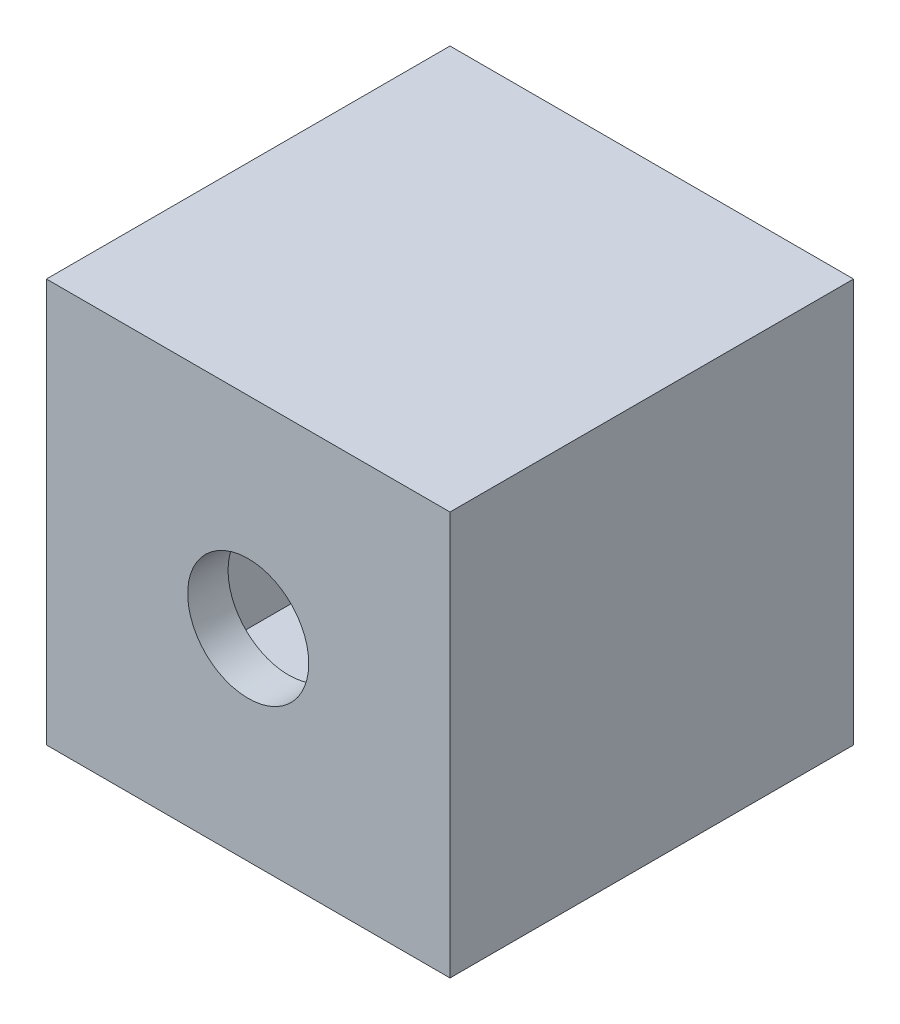
from build123d import *

# Parameters (mm, degrees)
SKETCH5_W           = 200
SKETCH5_H           = 200
BOSS_EXTRUDE2_DEPTH = 200
SHELL2_T            = -20
SKETCH6_R           = 30
CUT_EXTRUDE2_DEPTH  = 51.6


with BuildPart() as part:
    # Sketch5 → Boss-Extrude2 (new body)
    with BuildSketch(Plane.XY):
        Rectangle(SKETCH5_W, SKETCH5_H)
    extrude(amount=BOSS_EXTRUDE2_DEPTH)

    # Shell2
    shell2_openings = [part.faces().sort_by_distance(p)[0] for p in [
        (0, 0, 0),
    ]]
    offset(amount=SHELL2_T, openings=shell2_openings, kind=Kind.INTERSECTION)

    # Sketch6 → Cut-Extrude2 (cut)
    with BuildSketch(Plane.XY.offset(200)):
        Circle(SKETCH6_R)
    extrude(amount=-CUT_EXTRUDE2_DEPTH, mode=Mode.SUBTRACT)


solid = part.part
